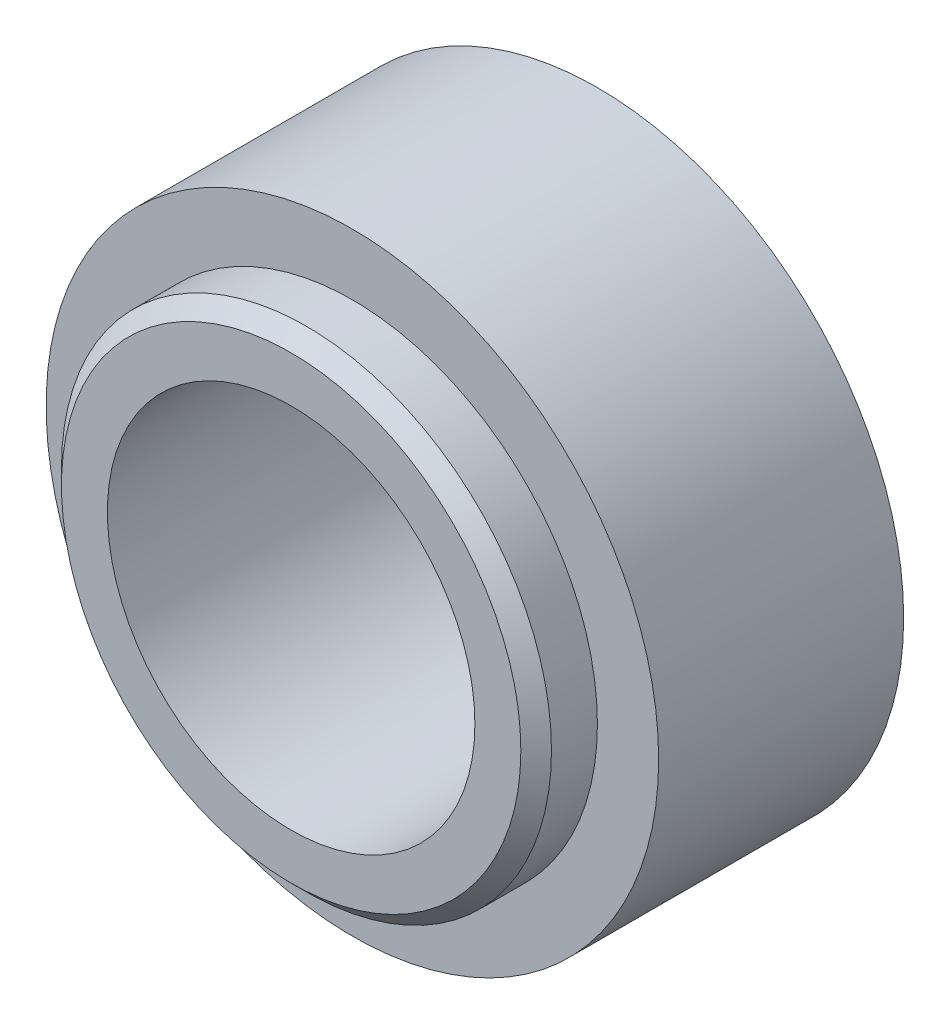
from build123d import *

# Parameters (mm, degrees)
SKETCH1_R           = 31.75
SKETCH1_R_2         = 25.4
BOSS_EXTRUDE3_DEPTH = 25.4
SKETCH1_3_R         = 25.4
SKETCH1_3_R_2       = 19.05
BOSS_EXTRUDE4_DEPTH = 31.75
CHAMFER1_SIZE       = 1.5875


with BuildPart() as part:
    # Sketch1 → Boss-Extrude3 (new body)
    with BuildSketch(Plane.XY):
        Circle(SKETCH1_R)
        Circle(SKETCH1_R_2, mode=Mode.SUBTRACT)
    extrude(amount=BOSS_EXTRUDE3_DEPTH)

    # Sketch1_3 → Boss-Extrude4 (add)
    with BuildSketch(Plane.XY):
        Circle(SKETCH1_3_R)
        Circle(SKETCH1_3_R_2, mode=Mode.SUBTRACT)
    extrude(amount=BOSS_EXTRUDE4_DEPTH)

    # Chamfer1
    chamfer1_edges = [part.edges().sort_by_distance(p)[0] for p in [
        (-19.05, 0, 0),
        (-25.4, 0, 31.75),
    ]]
    chamfer(chamfer1_edges, length=CHAMFER1_SIZE)


solid = part.part
